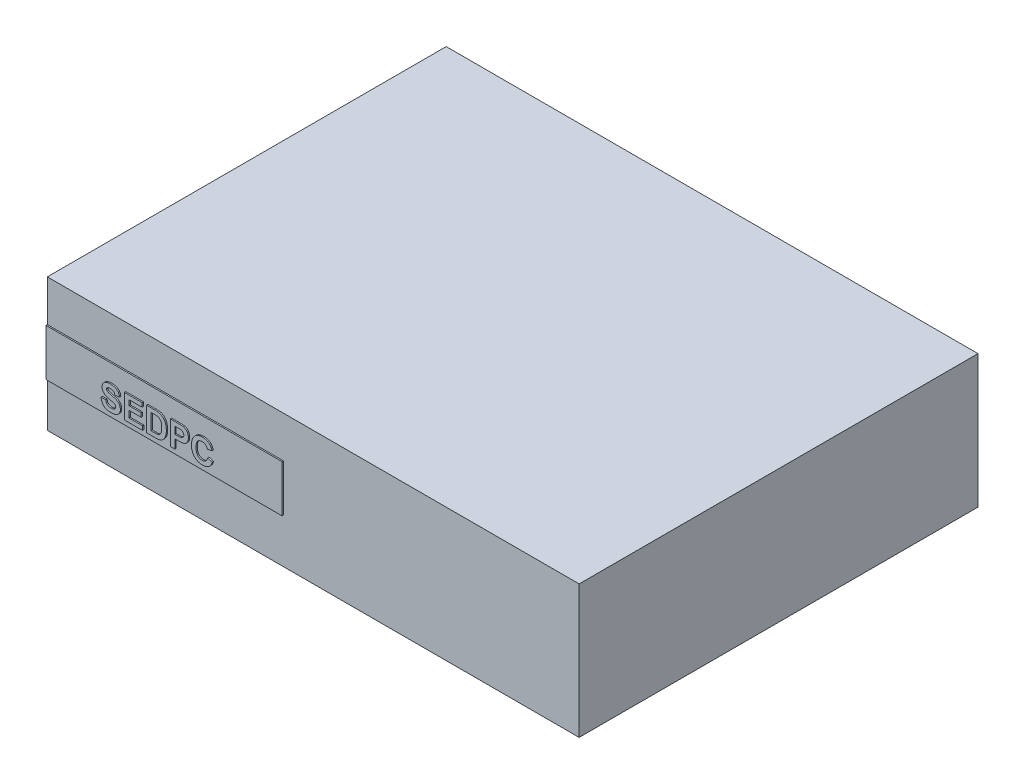
from build123d import *

# Parameters (mm, degrees)
CROQUIS1_W              = 400
CROQUIS1_H              = 100
SALIENTE_EXTRUIR1_DEPTH = 300
CROQUIS2_W              = 177.583537636
CROQUIS2_H              = 35.28517224
SALIENTE_EXTRUIR2_DEPTH = 1
SALIENTE_EXTRUIR3_DEPTH = 1


with BuildPart() as part:
    # Croquis1 → Saliente-Extruir1 (new body)
    with BuildSketch(Plane.XY):
        with Locations((200, -50)):
            Rectangle(CROQUIS1_W, CROQUIS1_H)
    extrude(amount=SALIENTE_EXTRUIR1_DEPTH)

    # Croquis2 → Saliente-Extruir2 (add)
    with BuildSketch(Plane.XY.offset(300)):
        with Locations((88.791768818, -48.75464098)):
            Rectangle(CROQUIS2_W, CROQUIS2_H)
    extrude(amount=SALIENTE_EXTRUIR2_DEPTH)

    # Croquis3 → Saliente-Extruir3 (add)
    with BuildSketch(Plane.XY.offset(301)):
        with BuildLine():
            Line((42.410185463, -56.253286768), (45.867537539, -56.022796629))
            add(Edge.make_bspline(
                [(45.867537539, -56.022796629), (45.895081284, -56.167440065), (45.948583258, -56.448400739), (46.067454596, -56.848808057), (46.19829904, -57.222101239), (46.354665323, -57.56427734), (46.52584646, -57.881661292), (46.72590505, -58.165211594), (46.940884497, -58.423981283), (47.181426696, -58.648676457), (47.443494301, -58.845467594), (47.728395002, -59.013297632), (48.033041656, -59.158557561), (48.358179157, -59.278174508), (48.707158548, -59.367469142), (49.076939705, -59.430996981), (49.468052963, -59.471678453), (49.735347728, -59.477279071), (49.872303694, -59.480148705)],
                knots=[0, 0, 0, 0, 0.000441448, 0.000857485, 0.001251638, 0.001627187, 0.001985034, 0.002331705, 0.002666481, 0.002992603, 0.00331673, 0.003647785, 0.003982851, 0.00432808, 0.004685346, 0.005061913, 0.005452877, 0.00586369, 0.00586369, 0.00586369, 0.00586369], degree=3))
            add(Edge.make_bspline(
                [(49.872303694, -59.480148705), (50.01645851, -59.478575985), (50.296847054, -59.475516964), (50.703161056, -59.437567116), (51.083083102, -59.383199875), (51.43325835, -59.297137808), (51.760225987, -59.200891003), (52.055865497, -59.069215121), (52.32496103, -58.917346028), (52.566819335, -58.745013954), (52.777889304, -58.55388532), (52.962543847, -58.354353227), (53.123365755, -58.150728481), (53.249943979, -57.933975108), (53.352382038, -57.712859512), (53.420086422, -57.480785432), (53.465824741, -57.243081791), (53.471069594, -57.080627553), (53.473712106, -56.998778309)],
                knots=[0, 0, 0, 0, 0.000432304, 0.000840854, 0.001223367, 0.001582389, 0.00192184, 0.002244362, 0.002550799, 0.002847626, 0.003133252, 0.003403382, 0.003662708, 0.003909766, 0.004154768, 0.00439175, 0.00463334, 0.004878659, 0.004878659, 0.004878659, 0.004878659], degree=3))
            add(Edge.make_bspline(
                [(53.473712106, -56.998778309), (53.47047129, -56.896227845), (53.464131108, -56.695602869), (53.387801666, -56.408787489), (53.273333377, -56.143061328), (53.100983689, -55.902349161), (52.869303287, -55.682373323), (52.573771846, -55.47659131), (52.206140066, -55.291467981), (51.933405107, -55.188205843), (51.788252969, -55.133248751)],
                knots=[0, 0, 0, 0, 0.000306881, 0.000600369, 0.000884127, 0.001170908, 0.001481633, 0.001838336, 0.002247457, 0.002712917, 0.002712917, 0.002712917, 0.002712917], degree=3))
            add(Edge.make_bspline(
                [(51.788252969, -55.133248751), (51.72597203, -55.112378121), (51.586597403, -55.065673041), (51.348839088, -54.99888918), (51.06245288, -54.915493881), (50.72330032, -54.820701812), (50.331495446, -54.723754479), (49.891414204, -54.604326363), (49.397691518, -54.485485628), (49.052282532, -54.397757423), (48.871112155, -54.351743126)],
                knots=[0, 0, 0, 0, 0.000197027, 0.000440914, 0.000740698, 0.001091941, 0.00149724, 0.001951474, 0.002459835, 0.003020603, 0.003020603, 0.003020603, 0.003020603], degree=3))
            add(Edge.make_bspline(
                [(48.871112155, -54.351743126), (48.635174555, -54.292835013), (48.179971537, -54.179181443), (47.530747796, -53.976999795), (46.932800858, -53.776121133), (46.391887982, -53.558157006), (45.902042675, -53.337879429), (45.471188334, -53.099823455), (45.090333971, -52.856352179), (44.868401294, -52.674375799), (44.761905157, -52.587053004)],
                knots=[0, 0, 0, 0, 0.000729381, 0.001407221, 0.002039317, 0.002621142, 0.003156154, 0.003649376, 0.00409688, 0.004509724, 0.004509724, 0.004509724, 0.004509724], degree=3))
            add(Edge.make_bspline(
                [(44.761905157, -52.587053004), (44.629836103, -52.463397317), (44.37090251, -52.220958907), (44.030056623, -51.822586071), (43.743653267, -51.401768909), (43.507911949, -50.961613612), (43.326395594, -50.499586226), (43.197739135, -50.018779369), (43.114468001, -49.517938187), (43.105970755, -49.176853476), (43.101655879, -49.003651634)],
                knots=[0, 0, 0, 0, 0.000542475, 0.001063573, 0.001569016, 0.002066858, 0.002558408, 0.003054632, 0.003557902, 0.004077117, 0.004077117, 0.004077117, 0.004077117], degree=3))
            add(Edge.make_bspline(
                [(43.101655879, -49.003651634), (43.110059136, -48.779530515), (43.126728691, -48.334941116), (43.279599368, -47.681455389), (43.517730113, -47.050891992), (43.793905312, -46.550201306), (44.059250091, -46.171426907), (44.279599614, -45.899621866), (44.521674853, -45.645238476), (44.788791725, -45.414481955), (45.07103152, -45.193835571), (45.379329294, -44.997898939), (45.70494387, -44.813337472), (46.17614526, -44.59454844), (46.815907451, -44.366548778), (47.648272432, -44.174359532), (48.554553073, -44.058828972), (49.182880232, -44.044655815), (49.508561444, -44.037309433)],
                knots=[0, 0, 0, 0, 0.000671496, 0.001332048, 0.002002258, 0.002688919, 0.003040606, 0.003388771, 0.003737736, 0.004092452, 0.004446857, 0.004811472, 0.005187159, 0.005568993, 0.006368684, 0.007219532, 0.00812723, 0.009104015, 0.009104015, 0.009104015, 0.009104015], degree=3))
            add(Edge.make_bspline(
                [(49.508561444, -44.037309433), (49.775229497, -44.040875454), (50.293893158, -44.047811288), (51.045756382, -44.117947541), (51.748037427, -44.227106326), (52.398271907, -44.383803251), (52.996762785, -44.59084102), (53.545829985, -44.837462147), (54.045006936, -45.13026331), (54.488216651, -45.47092479), (54.883074025, -45.846482223), (55.227523934, -46.256699937), (55.522883282, -46.696397135), (55.771058278, -47.165252489), (55.965949449, -47.6656766), (56.10908932, -48.19704504), (56.203763272, -48.758107096), (56.227493586, -49.142552422), (56.239593767, -49.338582616)],
                knots=[0, 0, 0, 0, 0.000799805, 0.001555603, 0.00226314, 0.00293048, 0.003559171, 0.004160347, 0.004733526, 0.005291047, 0.005833618, 0.006365286, 0.006894681, 0.007419857, 0.007953546, 0.008502203, 0.00906822, 0.009657114, 0.009657114, 0.009657114, 0.009657114], degree=3))
            Line((56.239593767, -49.338582616), (52.782241691, -49.569072754))
            add(Edge.make_bspline(
                [(52.782241691, -49.569072754), (52.7622971, -49.460659466), (52.723427167, -49.249373242), (52.638913286, -48.946768441), (52.54358573, -48.666893516), (52.432009764, -48.409750262), (52.29723948, -48.179944357), (52.150570678, -47.970245988), (51.987957441, -47.783449267), (51.804015575, -47.624669289), (51.605066115, -47.480186016), (51.378333846, -47.364379329), (51.133319099, -47.256936215), (50.860700551, -47.17616534), (50.565713466, -47.11209498), (50.248186019, -47.064597379), (49.907460017, -47.041406377), (49.673053085, -47.036315231), (49.551778345, -47.033681232)],
                knots=[0, 0, 0, 0, 0.000330546, 0.000644199, 0.000941463, 0.001217176, 0.001483413, 0.001739214, 0.001984163, 0.002224029, 0.00246685, 0.002719796, 0.002986033, 0.003268554, 0.003570901, 0.003891264, 0.004230734, 0.004594636, 0.004594636, 0.004594636, 0.004594636], degree=3))
            add(Edge.make_bspline(
                [(49.551778345, -47.033681232), (49.425685734, -47.036006619), (49.180366927, -47.040530764), (48.822872039, -47.068294776), (48.487515011, -47.11954447), (48.172648811, -47.186258857), (47.878694026, -47.277019167), (47.60627099, -47.387686497), (47.354133347, -47.517976014), (47.200390806, -47.620483306), (47.124429075, -47.671130521)],
                knots=[0, 0, 0, 0, 0.000378302, 0.000736004, 0.001074709, 0.001395416, 0.001700708, 0.001996309, 0.002276595, 0.002550326, 0.002550326, 0.002550326, 0.002550326], degree=3))
            add(Edge.make_bspline(
                [(47.124429075, -47.671130521), (47.037497252, -47.740316055), (46.869137293, -47.87430696), (46.687946351, -48.14036734), (46.578868986, -48.440874562), (46.565740288, -48.653383637), (46.559007954, -48.76235727)],
                knots=[0, 0, 0, 0, 0.000331682, 0.000642364, 0.000952211, 0.001278333, 0.001278333, 0.001278333, 0.001278333], degree=3))
            add(Edge.make_bspline(
                [(46.559007954, -48.76235727), (46.564513776, -48.864200365), (46.575359368, -49.064815055), (46.684751129, -49.349792564), (46.852980754, -49.613844724), (47.010163746, -49.757281318), (47.092016399, -49.831975568)],
                knots=[0, 0, 0, 0, 0.00030425, 0.000599324, 0.000903999, 0.001235055, 0.001235055, 0.001235055, 0.001235055], degree=3))
            add(Edge.make_bspline(
                [(47.092016399, -49.831975568), (47.156977027, -49.880455885), (47.30213699, -49.988789212), (47.56804127, -50.12649112), (47.888994714, -50.275630605), (48.272314285, -50.421430919), (48.715452449, -50.566960588), (49.218436156, -50.718910387), (49.781574762, -50.872900254), (50.390514142, -51.022031898), (51.008759118, -51.168619737), (51.598733263, -51.328881619), (52.147324376, -51.485124559), (52.651988798, -51.648892515), (53.115327979, -51.808320112), (53.535091182, -51.972063737), (53.914160663, -52.131531705), (54.356197703, -52.350811458), (54.857202229, -52.647834744), (55.382311489, -53.079607627), (55.846703623, -53.564948546), (56.170279719, -54.022591555), (56.392559566, -54.416176721), (56.535684334, -54.729909927), (56.659498485, -55.060505617), (56.760282867, -55.408329126), (56.833327293, -55.773869882), (56.893775806, -56.154335151), (56.924660073, -56.55288478), (56.928906504, -56.824667268), (56.931064182, -56.962764225)],
                knots=[0, 0, 0, 0, 0.000242821, 0.000542605, 0.000895506, 0.001304817, 0.001771752, 0.002294701, 0.002880945, 0.003522946, 0.004175438, 0.004786956, 0.005356844, 0.005886447, 0.006378485, 0.006826581, 0.007237994, 0.007611656, 0.008306504, 0.008979775, 0.009644672, 0.010316197, 0.010654806, 0.010999658, 0.011349514, 0.011713114, 0.012084635, 0.012467148, 0.012868216, 0.013282519, 0.013282519, 0.013282519, 0.013282519], degree=3))
            add(Edge.make_bspline(
                [(56.931064182, -56.962764225), (56.928097305, -57.090120493), (56.922205375, -57.343037706), (56.881030971, -57.718430697), (56.817355788, -58.087157403), (56.723094641, -58.449680069), (56.59804761, -58.805285533), (56.457254589, -59.159106168), (56.281200844, -59.503425888), (56.080827671, -59.838529875), (55.859806956, -60.164166655), (55.609349434, -60.464559168), (55.344165999, -60.749729231), (55.047312139, -61.003708913), (54.737119243, -61.247063088), (54.39939941, -61.462581635), (54.042064923, -61.65760684), (53.662856418, -61.83068264), (53.260429391, -61.981502557), (52.835306513, -62.115742768), (52.383657681, -62.22560807), (51.909249002, -62.319776474), (51.410344354, -62.391389113), (50.887567474, -62.441391386), (50.34079952, -62.469589654), (49.968372672, -62.474181516), (49.778667075, -62.476520504)],
                knots=[0, 0, 0, 0, 0.000382021, 0.000758657, 0.001131676, 0.001503791, 0.001880771, 0.002261976, 0.002645302, 0.003039356, 0.003432949, 0.003824444, 0.004211658, 0.004599575, 0.004995042, 0.005393628, 0.005799758, 0.006215545, 0.006642961, 0.007088329, 0.007552142, 0.008036662, 0.008538849, 0.009063482, 0.009611653, 0.010180778, 0.010180778, 0.010180778, 0.010180778], degree=3))
            add(Edge.make_bspline(
                [(49.778667075, -62.476520504), (49.504761463, -62.472048529), (48.97146074, -62.463341488), (48.19667057, -62.385406619), (47.469968682, -62.266121681), (46.792538092, -62.092998998), (46.163550814, -61.870748549), (45.583293724, -61.596985073), (45.054573456, -61.270072976), (44.570841531, -60.897940426), (44.138542915, -60.473806229), (43.749819128, -60.006458288), (43.409914164, -59.491688215), (43.119051441, -58.930301174), (42.869877446, -58.32533202), (42.664381254, -57.676502957), (42.509653422, -56.980719422), (42.443914882, -56.499957966), (42.410185463, -56.253286768)],
                knots=[0, 0, 0, 0, 0.000821508, 0.001599496, 0.002333662, 0.003028958, 0.003694195, 0.004332123, 0.004949804, 0.005555633, 0.006159221, 0.006762819, 0.007376117, 0.008005962, 0.008656712, 0.009336692, 0.010045291, 0.010791973, 0.010791973, 0.010791973, 0.010791973], degree=3))
        make_face()
        Polygon((59.927435981, -62.246030366), (59.927435981, -44.267799571), (73.295864007, -44.267799571), (73.295864007, -47.26417137), (63.384788057, -47.26417137), (63.384788057, -51.182503723), (72.604393592, -51.182503723), (72.604393592, -54.178875522), (63.384788057, -54.178875522), (63.384788057, -59.249658567), (73.526354146, -59.249658567), (73.526354146, -62.246030366), align=None)
        with BuildLine():
            Line((76.522725945, -44.267799571), (83.116904748, -44.267799571))
            add(Edge.make_bspline(
                [(83.116904748, -44.267799571), (83.297002476, -44.267706207), (83.647694589, -44.267524404), (84.156640658, -44.288638274), (84.632570664, -44.30987605), (85.074118572, -44.352389433), (85.482816244, -44.396950996), (85.859397077, -44.453369289), (86.201482187, -44.525675506), (86.417200863, -44.582697607), (86.520235697, -44.609933371)],
                knots=[0, 0, 0, 0, 0.000540223, 0.00105194, 0.001527994, 0.001969148, 0.00238237, 0.002761323, 0.003110956, 0.003430651, 0.003430651, 0.003430651, 0.003430651], degree=3))
            add(Edge.make_bspline(
                [(86.520235697, -44.609933371), (86.649087053, -44.651928038), (86.904468848, -44.73516095), (87.278866414, -44.880998868), (87.633588613, -45.0618673), (87.981795219, -45.251993669), (88.307941292, -45.476795987), (88.629287125, -45.710672707), (88.924977885, -45.981594419), (89.312738291, -46.360225351), (89.755202389, -46.887670217), (90.218750954, -47.587299326), (90.611098681, -48.355238528), (90.879168686, -49.043285315), (91.060179962, -49.628183203), (91.178505059, -50.097122999), (91.27901503, -50.591091266), (91.361534028, -51.110212533), (91.425648913, -51.65448687), (91.473383128, -52.223769207), (91.496634506, -52.818551325), (91.501899, -53.223286869), (91.50458494, -53.429782572)],
                knots=[0, 0, 0, 0, 0.000406577, 0.00080583, 0.001203651, 0.001600329, 0.001994877, 0.002391032, 0.002791501, 0.003196415, 0.004016754, 0.004850797, 0.005709301, 0.006598783, 0.007062414, 0.007545446, 0.008049039, 0.008574215, 0.009121878, 0.009692823, 0.01028759, 0.010907126, 0.010907126, 0.010907126, 0.010907126], degree=3))
            add(Edge.make_bspline(
                [(91.50458494, -53.429782572), (91.499681866, -53.786670528), (91.490199419, -54.476884669), (91.38034467, -55.472860793), (91.2220301, -56.39794188), (91.04357674, -56.975047683), (90.957170861, -57.254478306)],
                knots=[0, 0, 0, 0, 0.001070109, 0.00206957, 0.003003398, 0.003879991, 0.003879991, 0.003879991, 0.003879991], degree=3))
            add(Edge.make_bspline(
                [(90.957170861, -57.254478306), (90.900114352, -57.41482169), (90.787875297, -57.730242139), (90.591465366, -58.185237686), (90.379243049, -58.618233245), (90.149448046, -59.028887667), (89.900919366, -59.415353819), (89.632727427, -59.776475756), (89.349029408, -60.117007761), (89.143506608, -60.326606822), (89.041221586, -60.430920526)],
                knots=[0, 0, 0, 0, 0.000510461, 0.001004156, 0.001485736, 0.001956571, 0.002415097, 0.002863121, 0.003305332, 0.003743463, 0.003743463, 0.003743463, 0.003743463], degree=3))
            add(Edge.make_bspline(
                [(89.041221586, -60.430920526), (88.875699708, -60.579775651), (88.534370003, -60.886736139), (87.932888604, -61.26661201), (87.25304549, -61.602280772), (86.761288549, -61.774708244), (86.505830064, -61.864281074)],
                knots=[0, 0, 0, 0, 0.000666805, 0.001375048, 0.002125602, 0.002937015, 0.002937015, 0.002937015, 0.002937015], degree=3))
            add(Edge.make_bspline(
                [(86.505830064, -61.864281074), (86.402995059, -61.895864766), (86.189566326, -61.961415086), (85.851154027, -62.031424183), (85.489890407, -62.105179459), (85.101609596, -62.149610776), (84.690342138, -62.196465565), (84.252810609, -62.22277191), (83.790531701, -62.241447887), (83.473465933, -62.244480224), (83.311380802, -62.246030366)],
                knots=[0, 0, 0, 0, 0.000322542, 0.00066942, 0.001036004, 0.00142821, 0.001841039, 0.002277761, 0.002742691, 0.003228935, 0.003228935, 0.003228935, 0.003228935], degree=3))
            Line((83.311380802, -62.246030366), (76.522725945, -62.246030366))
            Line((76.522725945, -62.246030366), (76.522725945, -44.267799571))
        make_face()
        with BuildLine():
            Line((79.980078021, -47.26417137), (79.980078021, -59.249658567))
            Line((79.980078021, -59.249658567), (82.825190666, -59.249658567))
            add(Edge.make_bspline(
                [(82.825190666, -59.249658567), (82.953640044, -59.248639875), (83.200954164, -59.246678505), (83.55882403, -59.240915258), (83.887703428, -59.225313052), (84.189315226, -59.209151712), (84.462874214, -59.182450349), (84.709570692, -59.15618854), (84.928031423, -59.119448819), (85.062958139, -59.090446969), (85.126490642, -59.076790963)],
                knots=[0, 0, 0, 0, 0.000385368, 0.00074198, 0.001073622, 0.001373081, 0.001647947, 0.001898108, 0.002117174, 0.002312116, 0.002312116, 0.002312116, 0.002312116], degree=3))
            add(Edge.make_bspline(
                [(85.126490642, -59.076790963), (85.275290965, -59.037083655), (85.565114746, -58.959744292), (85.972056635, -58.787332595), (86.340286616, -58.579336744), (86.675971415, -58.329230677), (86.978492905, -58.013154453), (87.236731977, -57.608917748), (87.475725432, -57.126808449), (87.639388206, -56.665309282), (87.756865033, -56.253109019), (87.836387206, -55.907139165), (87.899231429, -55.532834767), (87.953285658, -55.131673071), (87.99696276, -54.704169949), (88.02414072, -54.248781617), (88.042689845, -53.766065515), (88.045689837, -53.434603304), (88.047232864, -53.264117785)],
                knots=[0, 0, 0, 0, 0.000461557, 0.000898991, 0.00132157, 0.001727811, 0.002150666, 0.00262612, 0.003160841, 0.003762374, 0.004091839, 0.004446536, 0.004826651, 0.005230041, 0.005660782, 0.006115473, 0.006598398, 0.007109849, 0.007109849, 0.007109849, 0.007109849], degree=3))
            add(Edge.make_bspline(
                [(88.047232864, -53.264117785), (88.045701703, -53.093631743), (88.042735557, -52.763368159), (88.024214881, -52.284251414), (87.997189583, -51.836034182), (87.953201428, -51.41816239), (87.899985127, -51.030058516), (87.83640479, -50.67139413), (87.757361989, -50.344523037), (87.63978524, -49.956194142), (87.461544946, -49.519700402), (87.218994691, -49.042461753), (86.921134631, -48.635697811), (86.592028267, -48.282335328), (86.21256307, -47.991535859), (85.792496014, -47.747974368), (85.322681039, -47.558931506), (84.988486888, -47.47841195), (84.816769518, -47.437038974)],
                knots=[0, 0, 0, 0, 0.000511451, 0.000990776, 0.001438279, 0.001858272, 0.002250958, 0.002613343, 0.002950512, 0.003259248, 0.003829704, 0.004362932, 0.004860721, 0.005337102, 0.005806793, 0.006289234, 0.00679014, 0.007319535, 0.007319535, 0.007319535, 0.007319535], degree=3))
            add(Edge.make_bspline(
                [(84.816769518, -47.437038974), (84.742441875, -47.423227858), (84.578800855, -47.392821065), (84.307254331, -47.357305755), (83.988669752, -47.33095036), (83.621423035, -47.304043816), (83.207001195, -47.288686408), (82.743670194, -47.272658458), (82.233368848, -47.26718334), (81.876818506, -47.265204211), (81.690747017, -47.26417137)],
                knots=[0, 0, 0, 0, 0.000226774, 0.00049927, 0.000821088, 0.001185703, 0.001603854, 0.002065059, 0.00257651, 0.00313474, 0.00313474, 0.00313474, 0.00313474], degree=3))
            Line((81.690747017, -47.26417137), (79.980078021, -47.26417137))
        make_face(mode=Mode.SUBTRACT)
        with BuildLine():
            Line((94.500956739, -62.246030366), (94.500956739, -44.267799571))
            Line((94.500956739, -44.267799571), (100.252405974, -44.267799571))
            add(Edge.make_bspline(
                [(100.252405974, -44.267799571), (100.512916364, -44.268084061), (101.011173455, -44.268628181), (101.721907057, -44.283746123), (102.361816187, -44.305147235), (102.929951115, -44.331801414), (103.42831096, -44.371574569), (103.854660136, -44.417631284), (104.211683336, -44.467176088), (104.421923721, -44.518448333), (104.516473534, -44.541506611)],
                knots=[0, 0, 0, 0, 0.000781514, 0.001494738, 0.002132554, 0.002702305, 0.003200876, 0.003631993, 0.003989042, 0.004280845, 0.004280845, 0.004280845, 0.004280845], degree=3))
            add(Edge.make_bspline(
                [(104.516473534, -44.541506611), (104.642201792, -44.577356582), (104.891742928, -44.648510376), (105.24925756, -44.800198963), (105.593845053, -44.975997943), (105.921176033, -45.18551855), (106.232363203, -45.425041054), (106.528331552, -45.692612118), (106.810659438, -45.989439613), (107.075441216, -46.314937174), (107.317950177, -46.667463474), (107.52753885, -47.047539715), (107.703130335, -47.45351389), (107.852731363, -47.882335155), (107.963107714, -48.338601168), (108.040351093, -48.81914174), (108.094122123, -49.324167052), (108.097929278, -49.669765186), (108.099874904, -49.846381202)],
                knots=[0, 0, 0, 0, 0.000391876, 0.000777781, 0.001162745, 0.00155138, 0.001941796, 0.002339585, 0.002747165, 0.003169575, 0.003597113, 0.004029117, 0.004469388, 0.004922679, 0.005389989, 0.005875485, 0.006382197, 0.0069118, 0.0069118, 0.0069118, 0.0069118], degree=3))
            add(Edge.make_bspline(
                [(108.099874904, -49.846381202), (108.09432599, -50.114592702), (108.083644025, -50.630914567), (107.964131793, -51.371124542), (107.781846238, -52.047258635), (107.51542273, -52.652804273), (107.190597126, -53.190137719), (106.832795037, -53.674541282), (106.424237632, -54.091414548), (105.982827396, -54.447485087), (105.516337452, -54.738878444), (105.049003065, -54.987287144), (104.574518242, -55.178271689), (104.251015547, -55.261485191), (104.091507341, -55.302514947)],
                knots=[0, 0, 0, 0, 0.000803921, 0.001547592, 0.00224314, 0.002899526, 0.003524575, 0.00412385, 0.004701974, 0.005270609, 0.005821106, 0.006349471, 0.006857065, 0.007350773, 0.007350773, 0.007350773, 0.007350773], degree=3))
            add(Edge.make_bspline(
                [(104.091507341, -55.302514947), (103.977658207, -55.324171728), (103.737677816, -55.369821638), (103.357083272, -55.41532629), (102.941072808, -55.465694978), (102.487935346, -55.498548267), (101.998219063, -55.529313994), (101.472114119, -55.54383951), (100.910372374, -55.561339806), (100.523729413, -55.561654265), (100.324434142, -55.561816352)],
                knots=[0, 0, 0, 0, 0.000347569, 0.000732633, 0.001149433, 0.001604637, 0.002095275, 0.002621389, 0.003183394, 0.003781238, 0.003781238, 0.003781238, 0.003781238], degree=3))
            Line((100.324434142, -55.561816352), (97.958308815, -55.561816352))
            Line((97.958308815, -55.561816352), (97.958308815, -62.246030366))
            Line((97.958308815, -62.246030366), (94.500956739, -62.246030366))
        make_face()
        with BuildLine():
            Line((97.958308815, -47.26417137), (97.958308815, -52.565444553))
            Line((97.958308815, -52.565444553), (100.03272006, -52.565444553))
            add(Edge.make_bspline(
                [(100.03272006, -52.565444553), (100.211605722, -52.565212912), (100.553836501, -52.564769752), (101.044861752, -52.548862908), (101.489338274, -52.529445655), (101.888194786, -52.497306129), (102.239023685, -52.454947002), (102.544174385, -52.404280152), (102.804002533, -52.349909327), (103.084971302, -52.259808158), (103.385383091, -52.114032683), (103.706187576, -51.904516709), (103.988013939, -51.654015653), (104.222530827, -51.359810838), (104.409857898, -51.032932242), (104.543984218, -50.676729826), (104.630589456, -50.297107109), (104.638500055, -50.034132613), (104.642522828, -49.900402328)],
                knots=[0, 0, 0, 0, 0.000536622, 0.001026625, 0.001473722, 0.001871201, 0.002226775, 0.002533466, 0.002799093, 0.003022322, 0.003417001, 0.00379657, 0.004168928, 0.004542955, 0.004920416, 0.005294304, 0.005681418, 0.006081968, 0.006081968, 0.006081968, 0.006081968], degree=3))
            add(Edge.make_bspline(
                [(104.642522828, -49.900402328), (104.636861217, -49.737520929), (104.625884098, -49.421715374), (104.504837127, -48.971955557), (104.318075482, -48.56379307), (104.051059353, -48.209927691), (103.728510153, -47.912356008), (103.365978315, -47.664765788), (102.955721805, -47.491500267), (102.66537016, -47.424366274), (102.517691865, -47.390220665)],
                knots=[0, 0, 0, 0, 0.000487522, 0.000945241, 0.001386689, 0.001826784, 0.002265062, 0.002698564, 0.003137405, 0.003591639, 0.003591639, 0.003591639, 0.003591639], degree=3))
            add(Edge.make_bspline(
                [(102.517691865, -47.390220665), (102.454142521, -47.380056465), (102.313082679, -47.357495094), (102.078612516, -47.333949497), (101.801234276, -47.3125348), (101.480613606, -47.294952694), (101.118021368, -47.281207559), (100.712261568, -47.26916343), (100.264402853, -47.268195844), (99.951085204, -47.265550029), (99.787824288, -47.26417137)],
                knots=[0, 0, 0, 0, 0.000193037, 0.000428482, 0.000706631, 0.001027662, 0.001391689, 0.001795192, 0.002245382, 0.002735187, 0.002735187, 0.002735187, 0.002735187], degree=3))
            Line((99.787824288, -47.26417137), (97.958308815, -47.26417137))
        make_face(mode=Mode.SUBTRACT)
        with BuildLine():
            Line((122.620753622, -55.561816352), (126.078105698, -56.714267044))
            add(Edge.make_bspline(
                [(126.078105698, -56.714267044), (126.007841663, -56.940956911), (125.870242578, -57.38488698), (125.61758759, -58.021144179), (125.32868053, -58.610792733), (125.013911134, -59.160734086), (124.653704516, -59.656761472), (124.268226954, -60.11529806), (123.846016663, -60.526686196), (123.389156943, -60.891804342), (122.902045327, -61.214686263), (122.379023492, -61.487647565), (121.8278968, -61.722742061), (121.243076515, -61.913218169), (120.628443897, -62.065760619), (119.98111505, -62.166515736), (119.304118112, -62.234831034), (118.841854875, -62.242238075), (118.605183243, -62.246030366)],
                knots=[0, 0, 0, 0, 0.000711814, 0.001393955, 0.002051111, 0.002680534, 0.00329219, 0.003887513, 0.004475823, 0.005057391, 0.005639729, 0.006226129, 0.006824808, 0.007435244, 0.008069389, 0.008722446, 0.009399022, 0.010108829, 0.010108829, 0.010108829, 0.010108829], degree=3))
            add(Edge.make_bspline(
                [(118.605183243, -62.246030366), (118.313060473, -62.2399899), (117.738446251, -62.228108125), (116.898127376, -62.108501645), (116.097341484, -61.921887016), (115.334943001, -61.663522308), (114.616020829, -61.321318908), (113.934015949, -60.909350378), (113.293891747, -60.419253089), (112.697893885, -59.859287068), (112.156415417, -59.233727048), (111.688176622, -58.545953377), (111.288082764, -57.805655117), (110.964706278, -57.009302437), (110.711847688, -56.157713055), (110.534719722, -55.252064427), (110.423884304, -54.292071275), (110.411256912, -53.634175444), (110.404776288, -53.296530461)],
                knots=[0, 0, 0, 0, 0.000875883, 0.001722888, 0.002540535, 0.003340047, 0.00413266, 0.004924479, 0.005726178, 0.006546572, 0.007373925, 0.008203031, 0.00903772, 0.009893765, 0.010776844, 0.011698559, 0.012659028, 0.013671664, 0.013671664, 0.013671664, 0.013671664], degree=3))
            add(Edge.make_bspline(
                [(110.404776288, -53.296530461), (110.411227701, -52.940883166), (110.423813231, -52.247080184), (110.534856285, -51.238350048), (110.707244014, -50.2876807), (110.96052997, -49.400966669), (111.279154388, -48.571967567), (111.679734002, -47.808912805), (112.14330213, -47.101628778), (112.682323107, -46.463079133), (113.281037157, -45.896133394), (113.922633313, -45.394800089), (114.613097091, -44.97421739), (115.348650117, -44.630286866), (116.130278898, -44.3641365), (116.956445402, -44.172487346), (117.827825578, -44.060935215), (118.423592528, -44.045292435), (118.727631129, -44.037309433)],
                knots=[0, 0, 0, 0, 0.001066625, 0.002080791, 0.00304072, 0.003961836, 0.004843299, 0.00570026, 0.006542297, 0.007375538, 0.008200882, 0.009012023, 0.009813738, 0.01062092, 0.011443209, 0.012286223, 0.013161314, 0.014073331, 0.014073331, 0.014073331, 0.014073331], degree=3))
            add(Edge.make_bspline(
                [(118.727631129, -44.037309433), (118.993159788, -44.044000067), (119.51376406, -44.057117944), (120.276136151, -44.146241287), (120.998651542, -44.302646804), (121.685215664, -44.513759472), (122.331920215, -44.792372033), (122.939923765, -45.132833714), (123.511316168, -45.533343121), (123.855591854, -45.846188405), (124.028904312, -46.003678426)],
                knots=[0, 0, 0, 0, 0.000796571, 0.001561783, 0.002298525, 0.003011585, 0.003713352, 0.004406658, 0.005099122, 0.005801101, 0.005801101, 0.005801101, 0.005801101], degree=3))
            add(Edge.make_bspline(
                [(124.028904312, -46.003678426), (124.129353937, -46.103890926), (124.332612676, -46.306669843), (124.604020142, -46.649018113), (124.861348139, -47.017556084), (125.100512356, -47.418570543), (125.31395386, -47.855091958), (125.511943654, -48.320416751), (125.694225429, -48.81633859), (125.795595057, -49.161469548), (125.84761556, -49.338582616)],
                knots=[0, 0, 0, 0, 0.000425348, 0.000860686, 0.001308262, 0.001773346, 0.002259749, 0.002764794, 0.00329002, 0.003843677, 0.003843677, 0.003843677, 0.003843677], degree=3))
            Line((125.84761556, -49.338582616), (122.390263484, -50.030053031))
            add(Edge.make_bspline(
                [(122.390263484, -50.030053031), (122.360877413, -49.916651683), (122.302994562, -49.693280778), (122.18587649, -49.372309055), (122.051532827, -49.067735557), (121.88502616, -48.78702035), (121.708153024, -48.517675208), (121.49874521, -48.271659889), (121.270176241, -48.042526871), (121.020799539, -47.832654), (120.753588032, -47.646282079), (120.47368649, -47.478745331), (120.176007587, -47.341982993), (119.864511185, -47.231342583), (119.540437949, -47.138578935), (119.200902634, -47.081274506), (118.848821448, -47.037283224), (118.608936063, -47.034899495), (118.486336765, -47.033681232)],
                knots=[0, 0, 0, 0, 0.000351243, 0.000691858, 0.001023891, 0.001348198, 0.001669834, 0.001989387, 0.002315349, 0.002639976, 0.002965699, 0.00329182, 0.003617305, 0.003946533, 0.004282933, 0.004626957, 0.004978532, 0.005346035, 0.005346035, 0.005346035, 0.005346035], degree=3))
            add(Edge.make_bspline(
                [(118.486336765, -47.033681232), (118.317969366, -47.037081486), (117.989366581, -47.043717765), (117.509063265, -47.117707779), (117.051279616, -47.220968499), (116.617861848, -47.378647085), (116.211494007, -47.580316693), (115.827557695, -47.825468652), (115.468160162, -48.113052918), (115.133179937, -48.446476416), (114.832580715, -48.831767607), (114.568311093, -49.26972198), (114.349075752, -49.765311731), (114.171091519, -50.31367357), (114.030997652, -50.916111501), (113.930959601, -51.57339819), (113.875635552, -52.285983281), (113.866727915, -52.779035154), (113.862128364, -53.033627647)],
                knots=[0, 0, 0, 0, 0.00050466, 0.000984945, 0.001454912, 0.0019106, 0.002364792, 0.002813366, 0.003274572, 0.003743142, 0.004227997, 0.004736931, 0.005273734, 0.005850004, 0.006464116, 0.007127284, 0.007842687, 0.008606491, 0.008606491, 0.008606491, 0.008606491], degree=3))
            add(Edge.make_bspline(
                [(113.862128364, -53.033627647), (113.866682625, -53.303820667), (113.875457984, -53.824440999), (113.930770295, -54.575387675), (114.031448043, -55.266059956), (114.169680066, -55.897683543), (114.348561226, -56.469871559), (114.567425818, -56.981633843), (114.82761405, -57.433569725), (115.128721123, -57.825378272), (115.463134535, -58.161940605), (115.821796953, -58.451307584), (116.202592339, -58.69871521), (116.607812151, -58.902266252), (117.038997628, -59.056250351), (117.492605059, -59.167922319), (117.970298807, -59.238913964), (118.297608598, -59.246026836), (118.464728315, -59.249658567)],
                knots=[0, 0, 0, 0, 0.000810605, 0.001561911, 0.002257132, 0.002902839, 0.003499674, 0.004052957, 0.004569354, 0.0050599, 0.005531024, 0.005989423, 0.006439944, 0.006890912, 0.0073466, 0.007810414, 0.008290699, 0.008791761, 0.008791761, 0.008791761, 0.008791761], degree=3))
            add(Edge.make_bspline(
                [(118.464728315, -59.249658567), (118.588457657, -59.246571715), (118.831753039, -59.24050188), (119.191362372, -59.201977101), (119.53651399, -59.128458112), (119.868897304, -59.031242556), (120.189803728, -58.909265713), (120.494338392, -58.75279395), (120.788492878, -58.572952896), (121.066163716, -58.362192962), (121.33106906, -58.125574696), (121.572678453, -57.852102951), (121.796791222, -57.548348636), (122.000564162, -57.212281754), (122.190805973, -56.846778917), (122.352664674, -56.446145393), (122.503450562, -56.016855608), (122.580969653, -55.716145383), (122.620753622, -55.561816352)],
                knots=[0, 0, 0, 0, 0.000371225, 0.000729958, 0.001083117, 0.00142842, 0.001768176, 0.002111238, 0.002454053, 0.00280123, 0.003155653, 0.003517841, 0.003893839, 0.004286673, 0.004695794, 0.005128518, 0.005581809, 0.006059712, 0.006059712, 0.006059712, 0.006059712], degree=3))
        make_face()
    extrude(amount=SALIENTE_EXTRUIR3_DEPTH)


solid = part.part
